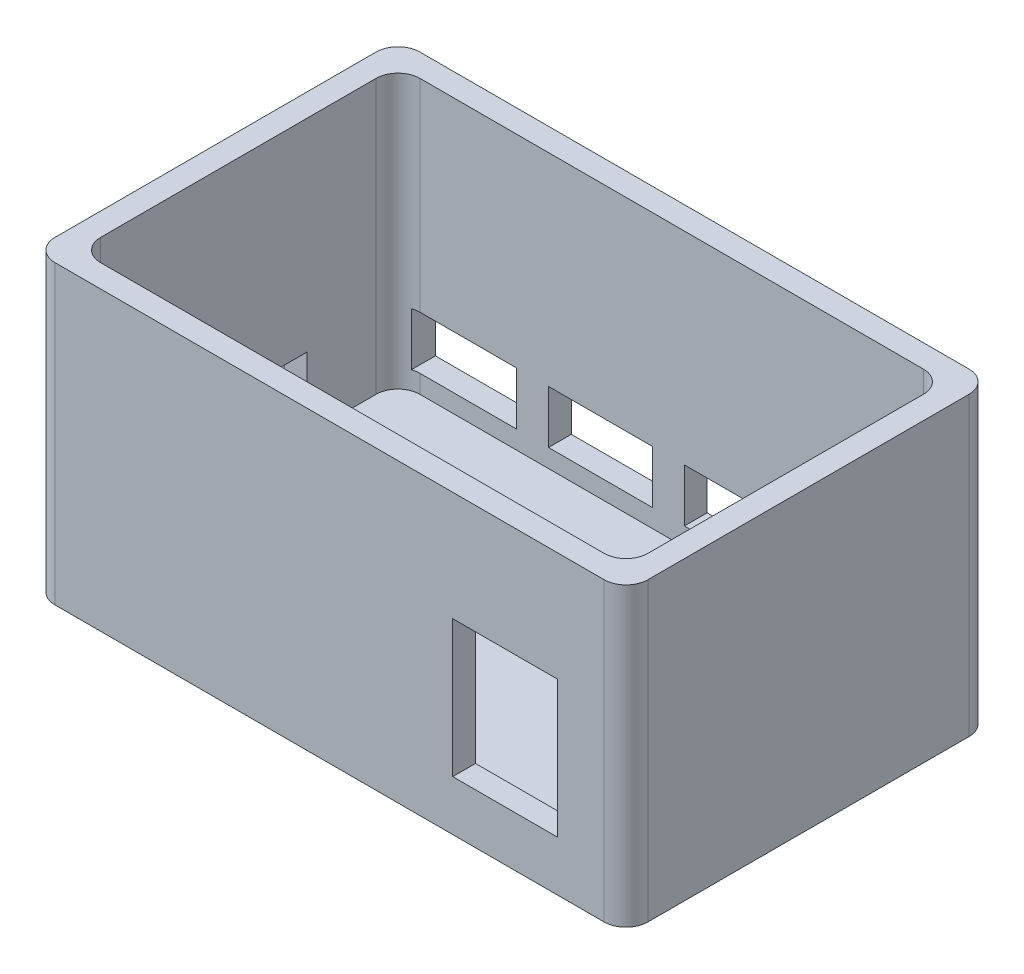
from build123d import *

# Parameters (mm, degrees)
SKETCH1_W           = 76.2
SKETCH1_H           = 44.45
BOSS_EXTRUDE1_DEPTH = 38.1
SHELL1_T            = 3.175
SKETCH3_W           = 25.4
SKETCH3_H           = 7.366
CUT_EXTRUDE2_DEPTH  = 12.7
FILLET1_R           = 3.048
SKETCH6_W           = 14.605
SKETCH6_H           = 19.05
CUT_EXTRUDE4_DEPTH  = 12.7
SKETCH5_W           = 14.478
SKETCH5_H           = 7.366
CUT_EXTRUDE5_DEPTH  = 12.7


with BuildPart() as part:
    # Sketch1 → Boss-Extrude1 (new body)
    with BuildSketch(Plane(origin=(0, 0, 0), x_dir=(1, 0, 0), z_dir=(0, 1, 0))):
        with Locations((38.1, -22.225)):
            Rectangle(SKETCH1_W, SKETCH1_H)
    extrude(amount=BOSS_EXTRUDE1_DEPTH)

    # Shell1
    shell1_openings = [part.faces().sort_by_distance(p)[0] for p in [
        (38.1, 38.1, 22.225),
    ]]
    offset(amount=SHELL1_T, openings=shell1_openings, kind=Kind.INTERSECTION)

    # Sketch3 → Cut-Extrude2 (cut)
    with BuildSketch(Plane.ZY.offset(3.175)):
        with Locations((25.4, 6.223)):
            Rectangle(SKETCH3_W, SKETCH3_H)
    extrude(amount=-CUT_EXTRUDE2_DEPTH, mode=Mode.SUBTRACT)

    # Fillet1
    fillet1_edges = [part.edges().sort_by_distance(p)[0] for p in [
        (0, 19.05, 0),
        (0, 19.05, 44.45),
        (76.2, 19.05, 44.45),
        (76.2, 19.05, 0),
        (-3.175, 17.4625, -3.175),
        (79.375, 17.4625, -3.175),
        (79.375, 17.4625, 47.625),
        (-3.175, 17.4625, 47.625),
    ]]
    fillet(fillet1_edges, radius=FILLET1_R)

    # Sketch6 → Cut-Extrude4 (cut)
    with BuildSketch(Plane.XY.offset(47.625)):
        with Locations((62.5475, 13.335)):
            Rectangle(SKETCH6_W, SKETCH6_H)
    extrude(amount=-CUT_EXTRUDE4_DEPTH, mode=Mode.SUBTRACT)

    # Sketch5 → Cut-Extrude5 (cut)
    with BuildSketch(Plane(origin=(0, 0, -3.175), x_dir=(-1, 0, 0), z_dir=(0, 0, -1))):
        with Locations((-47.117, 6.223)):
            Rectangle(SKETCH5_W, SKETCH5_H)
        with Locations((-28.194, 6.223)):
            Rectangle(SKETCH5_W, SKETCH5_H)
        with Locations((-9.271, 6.223)):
            Rectangle(SKETCH5_W, SKETCH5_H)
    extrude(amount=-CUT_EXTRUDE5_DEPTH, mode=Mode.SUBTRACT)


solid = part.part
